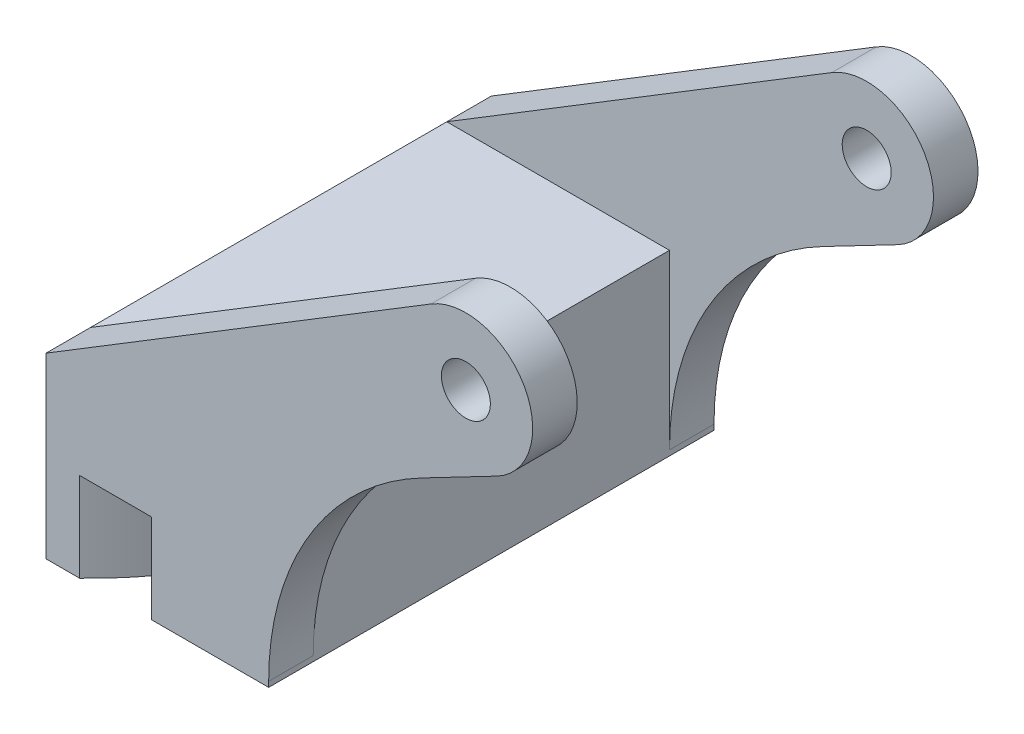
from build123d import *

# Parameters (mm, degrees)
SKETCH1_R               = 3.4925
BOSS_EXTRUDE1_DEPTH     = 63.5
SKETCH2_W               = 50.8
SKETCH2_H               = 34.925
CUT_EXTRUDE1_DEPTH      = 10.525
CUT_EXTRUDE1_DEPTH_BACK = 60.869090512
BOSS_EXTRUDE2_DEPTH     = 12.7
FILLET2_R               = 40.64


with BuildPart() as part:
    # Sketch1 → Boss-Extrude1 (new body)
    with BuildSketch(Plane.XY):
        with BuildLine():
            Line((-59.869090512, -25.4), (-4.964236422, 8.129082467))
            ThreePointArc((-4.964236422, 8.129082467), (8.292412041, 4.686312788), (4.403021401, -8.446243398))
            Line((4.403021401, -8.446243398), (-28.119090512, -25.4))
            Line((-28.119090512, -25.4), (-28.119090512, -38.1))
            Line((-28.119090512, -38.1), (-59.869090512, -38.1))
            Line((-59.869090512, -38.1), (-59.869090512, -25.4))
        make_face()
        Circle(SKETCH1_R, mode=Mode.SUBTRACT)
    extrude(amount=BOSS_EXTRUDE1_DEPTH)

    # Sketch2 → Cut-Extrude1 (cut, two sides)
    with BuildSketch(Plane(origin=(0, 0, 0), x_dir=(0, 0, -1), z_dir=(1, 0, 0))) as cut_extrude1_sk:
        with Locations((-31.75, -7.9375)):
            Rectangle(SKETCH2_W, SKETCH2_H)
    extrude(amount=CUT_EXTRUDE1_DEPTH, mode=Mode.SUBTRACT)
    extrude(cut_extrude1_sk.sketch, amount=-CUT_EXTRUDE1_DEPTH_BACK, mode=Mode.SUBTRACT)

    # Sketch3 → Boss-Extrude2 (add)
    with BuildSketch(Plane.XZ.offset(38.1)):
        with BuildLine():
            Line((-55.074857205, 63.5), (-59.869090512, 63.5))
            Line((-59.869090512, 63.5), (-59.869090512, 0))
            Line((-59.869090512, 0), (-55.074857205, 0))
            ThreePointArc((-55.074857205, 0), (-41.454090512, 31.75), (-55.074857205, 63.5))
        make_face()
        with BuildLine():
            Line((-44.803095838, 63.5), (-28.119090512, 63.5))
            Line((-28.119090512, 63.5), (-28.119090512, 0))
            Line((-28.119090512, 0), (-44.803095838, 0))
            ThreePointArc((-44.803095838, 0), (-33.834090512, 31.75), (-44.803095838, 63.5))
        make_face()
    extrude(amount=BOSS_EXTRUDE2_DEPTH)

    # Fillet2
    fillet2_edges = [part.edges().sort_by_distance(p)[0] for p in [
        (-28.119090512, -25.4, 60.325),
        (-28.119090512, -25.4, 3.175),
    ]]
    fillet(fillet2_edges, radius=FILLET2_R)


solid = part.part
